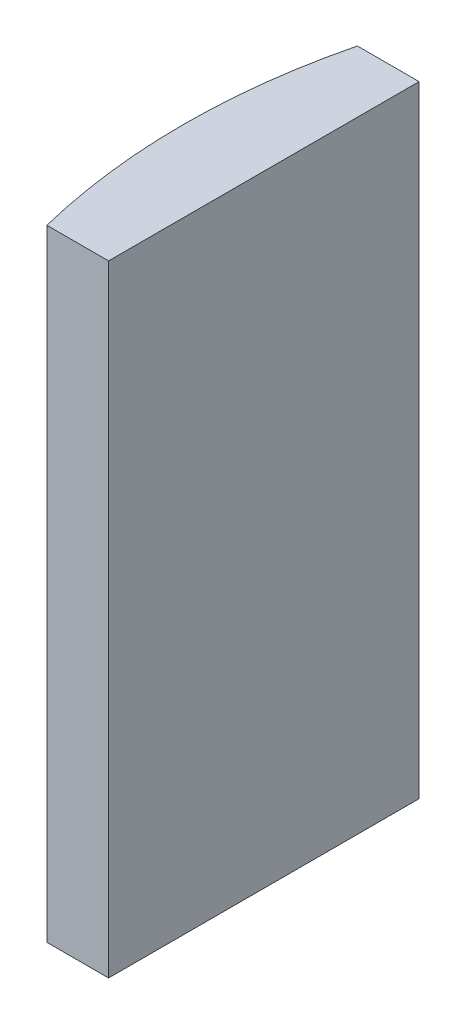
from build123d import *

# Parameters (mm, degrees)
EXTRUDE_1_DEPTH = 20


with BuildPart() as part:
    # 草图1 → 凸台-拉伸1 (new body)
    with BuildSketch(Plane(origin=(0, 0, 0), x_dir=(1, 0, 0), z_dir=(0, 1, 0))):
        with BuildLine():
            Line((-15.711245276, 5), (-13.724795665, 5))
            Line((-13.724795665, 5), (-13.724795665, -5))
            Line((-13.724795665, -5), (-15.711245276, -5))
            ThreePointArc((-15.711245276, -5), (-16.324795665, 0), (-15.711245276, 5))
        make_face()
    extrude(amount=EXTRUDE_1_DEPTH)


solid = part.part
